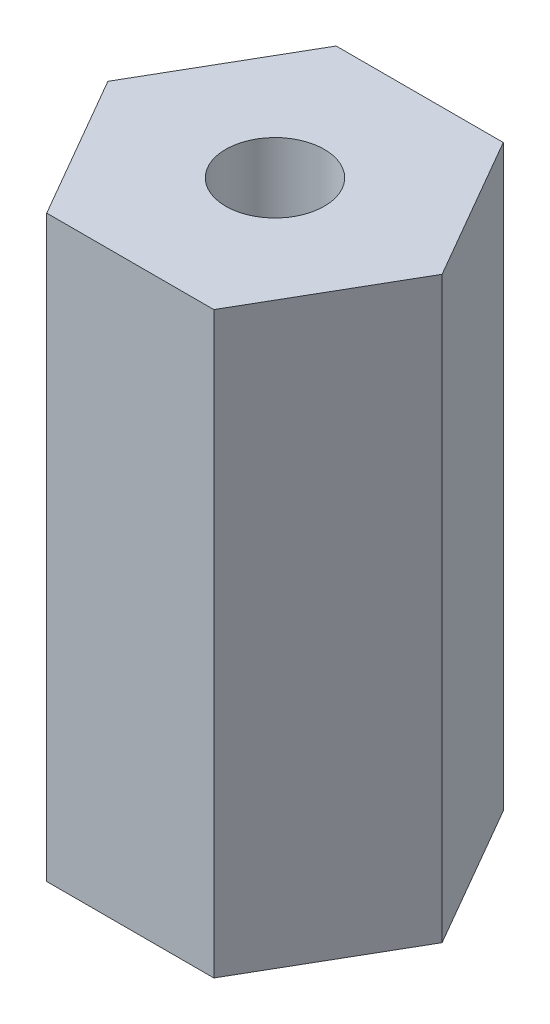
from build123d import *

# Parameters (mm, degrees)
BOSS_EXTRUDE1_DEPTH       = 15.875
F_6_32_TAPPED_HOLE1_D     = 2.7051
F_6_32_TAPPED_HOLE1_DEPTH = 5.08
F_6_32_TAPPED_HOLE1_TIP   = 0.81269403
F_6_32_TAPPED_HOLE2_D     = 2.7051
F_6_32_TAPPED_HOLE2_DEPTH = 5.08
F_6_32_TAPPED_HOLE2_TIP   = 0.81269403


with BuildPart() as part:
    # Sketch2 → Boss-Extrude1 (new body)
    with BuildSketch(Plane(origin=(0, 0, 0), x_dir=(1, 0, 0), z_dir=(0, 1, 0))):
        Polygon((4.582717762, 0), (2.291358881, 3.96875), (-2.291358881, 3.96875), (-4.582717762, 0), (-2.291358881, -3.96875), (2.291358881, -3.96875), align=None)
    extrude(amount=BOSS_EXTRUDE1_DEPTH)

    # #6-32 Tapped Hole1
    with Locations(Plane(origin=(0, 0, 0), x_dir=(-1, 0, 0), z_dir=(0, -1, 0))):
        with Locations((0, 0)):
            Hole(F_6_32_TAPPED_HOLE1_D / 2, depth=F_6_32_TAPPED_HOLE1_DEPTH)
            with Locations((0, 0, -(F_6_32_TAPPED_HOLE1_DEPTH + F_6_32_TAPPED_HOLE1_TIP / 2))):  # 118° drill point
                Cone(0, F_6_32_TAPPED_HOLE1_D / 2, F_6_32_TAPPED_HOLE1_TIP, mode=Mode.SUBTRACT)

    # #6-32 Tapped Hole2
    with Locations(Plane(origin=(0, 15.875, 0), x_dir=(1, 0, 0), z_dir=(0, 1, 0))):
        with Locations((0, 0)):
            Hole(F_6_32_TAPPED_HOLE2_D / 2, depth=F_6_32_TAPPED_HOLE2_DEPTH)
            with Locations((0, 0, -(F_6_32_TAPPED_HOLE2_DEPTH + F_6_32_TAPPED_HOLE2_TIP / 2))):  # 118° drill point
                Cone(0, F_6_32_TAPPED_HOLE2_D / 2, F_6_32_TAPPED_HOLE2_TIP, mode=Mode.SUBTRACT)


solid = part.part
